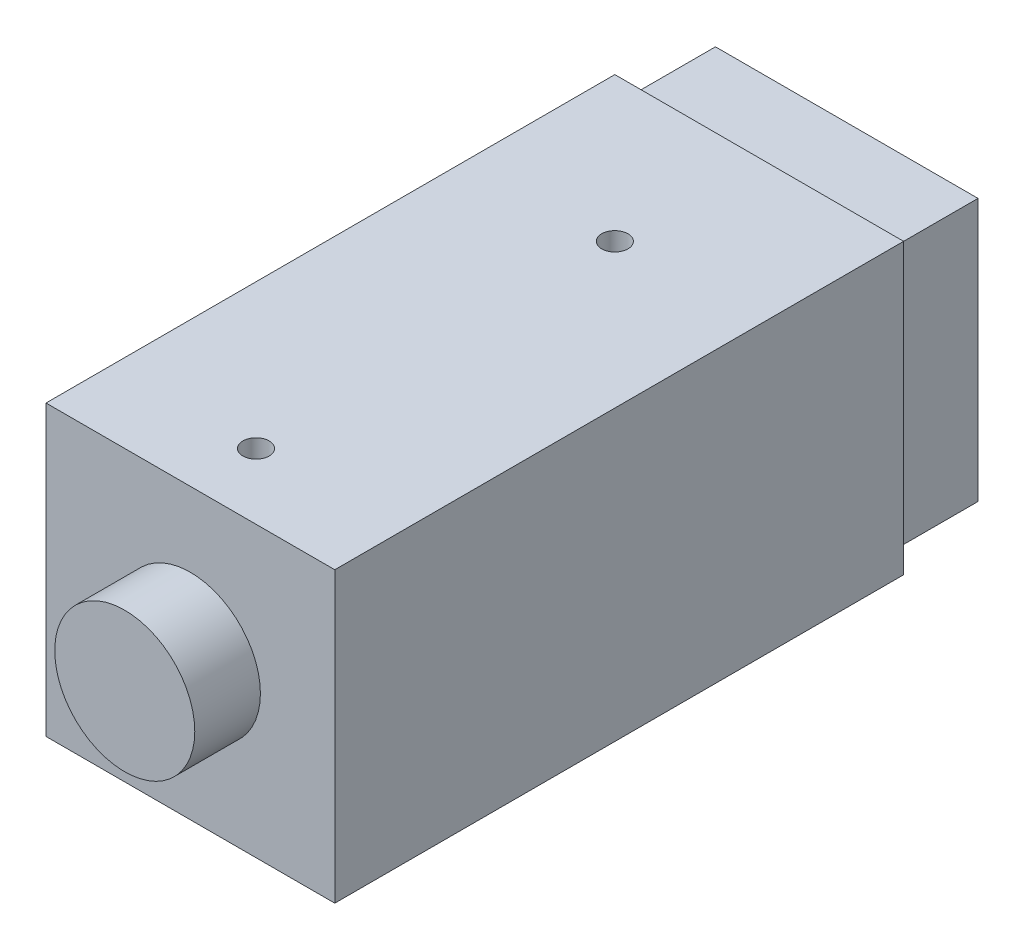
from build123d import *

# Parameters (mm, degrees)
ESBO_O1_W                = 33
ESBO_O1_H                = 33
RESSALTO_EXTRUS_O1_DEPTH = 65
ESBO_O2_W                = 30
ESBO_O2_H                = 30
RESSALTO_EXTRUS_O2_DEPTH = 10
ESBO_O3_R                = 8
RESSALTO_EXTRUS_O3_DEPTH = 7.5
ESBO_O4_R                = 1.5
CORTE_EXTRUS_O1_DEPTH    = 7.5


with BuildPart() as part:
    # Esboço1 → Ressalto-extrusão1 (new body)
    with BuildSketch(Plane.XY):
        Rectangle(ESBO_O1_W, ESBO_O1_H)
    extrude(amount=RESSALTO_EXTRUS_O1_DEPTH)

    # Esboço2 → Ressalto-extrusão2 (add)
    with BuildSketch(Plane(origin=(0, 0, 0), x_dir=(-1, 0, 0), z_dir=(0, 0, -1))):
        Rectangle(ESBO_O2_W, ESBO_O2_H)
    extrude(amount=RESSALTO_EXTRUS_O2_DEPTH)

    # Esboço3 → Ressalto-extrusão3 (add)
    with BuildSketch(Plane.XY.offset(65)):
        Circle(ESBO_O3_R)
    extrude(amount=RESSALTO_EXTRUS_O3_DEPTH)

    # Esboço4 → Corte-extrusão1 (cut)
    with BuildSketch(Plane(origin=(0, 16.5, 0), x_dir=(1, 0, 0), z_dir=(0, 1, 0))):
        with Locations((0, -16.5)):
            Circle(ESBO_O4_R)
        with Locations((0, -57.5)):
            Circle(ESBO_O4_R)
    extrude(amount=-CORTE_EXTRUS_O1_DEPTH, mode=Mode.SUBTRACT)


solid = part.part
